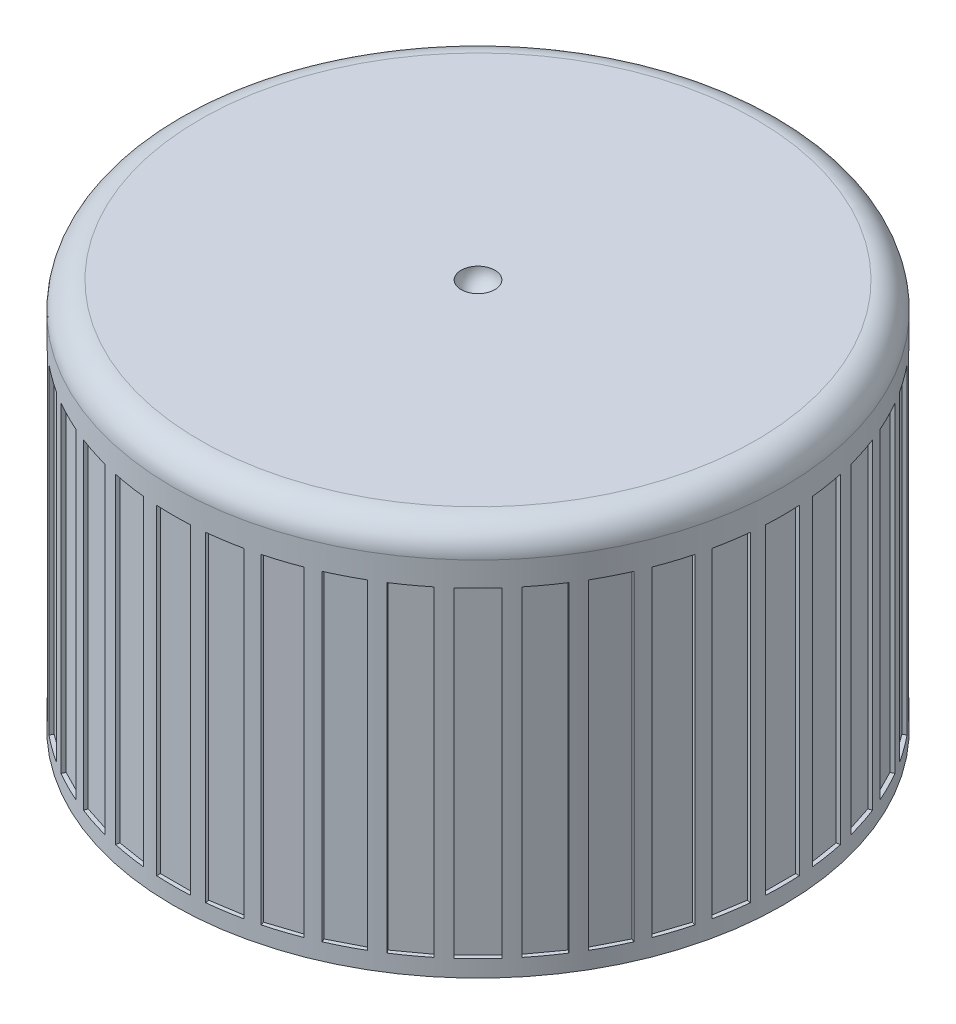
from build123d import *

# Parameters (mm, degrees)
CUT_EXTRUDE1_START = -0.5
SKETCH2_W          = 0.25
SKETCH2_H          = 1
SKETCH2_W_2        = 1
SKETCH2_H_2        = 0.25
CUT_EXTRUDE1_DEPTH = 9.5
FILLET2_R          = 0.8


with BuildPart() as part:
    # Sketch1 → Revolve1 (revolve)
    with BuildSketch(Plane.XY):
        with BuildLine():
            Line((8.23, 11.52), (0.5, 11.52))
            ThreePointArc((0.5, 11.52), (0.353553391, 11.166446609), (0, 11.02))
            Line((0, 11.02), (0, 7.53))
            Line((0, 7.53), (0, 7.23))
            Line((0, 7.23), (2, 7.23))
            Line((2, 7.23), (2, 7.53))
            Line((2, 7.53), (3.5, 7.53))
            ThreePointArc((3.5, 7.53), (3.9, 7.93), (4.3, 7.53))
            Line((4.3, 7.53), (5.51, 7.53))
            Line((5.51, 7.53), (5.51, 10.02))
            Line((5.51, 10.02), (6.73, 10.02))
            ThreePointArc((6.73, 10.02), (7.295685425, 9.785685425), (7.53, 9.22))
            Line((7.53, 9.22), (7.53, 2.04))
            Line((7.53, 2.04), (7.908578644, 1.661421356))
            ThreePointArc((7.908578644, 1.661421356), (7.967157288, 1.52), (7.908578644, 1.378578644))
            Line((7.908578644, 1.378578644), (7.53, 1))
            ThreePointArc((7.53, 1), (7.848120229, 0.29060024), (8.569230485, 0))
            Line((8.569230485, 0), (9.03, 0))
            Line((9.03, 0), (9.03, 10.72))
            ThreePointArc((9.03, 10.72), (8.795685425, 11.285685425), (8.23, 11.52))
        make_face()
    revolve(axis=Axis((0, 0, 0), (0, 1, 0)))

    # Sketch2 → Cut-Extrude1 (cut)
    with BuildSketch(Plane.XZ.offset(CUT_EXTRUDE1_START)):
        Polygon((8.873581906, -0.899204741), (9.120503991, -0.938313357), (8.964069526, -1.926001698), (8.71714744, -1.886893081), align=None)
        with Locations((9.03, 0)):
            Rectangle(SKETCH2_W, SKETCH2_H)
        Polygon((8.623666775, -2.276268077), (8.861430904, -2.353522325), (8.552413909, -3.304578842), (8.31464978, -3.227324593), align=None)
        Polygon((8.161408348, -3.597282138), (8.384159979, -3.710779763), (7.930169479, -4.601786287), (7.707417848, -4.488288662), align=None)
        Polygon((7.498188961, -4.829719174), (7.70044321, -4.976665488), (7.112657957, -5.785682482), (6.910403709, -5.638736169), align=None)
        Polygon((6.650339277, -5.943232496), (6.827115972, -6.120009191), (6.120009191, -6.827115972), (5.943232496, -6.650339277), align=None)
        Polygon((5.638736169, -6.910403709), (5.785682482, -7.112657957), (4.976665488, -7.70044321), (4.829719174, -7.498188961), align=None)
        Polygon((4.488288662, -7.707417848), (4.601786287, -7.930169479), (3.710779763, -8.384159979), (3.597282138, -8.161408348), align=None)
        Polygon((3.227324593, -8.31464978), (3.304578842, -8.552413909), (2.353522325, -8.861430904), (2.276268077, -8.623666775), align=None)
        Polygon((1.886893081, -8.71714744), (1.926001698, -8.964069526), (0.938313357, -9.120503991), (0.899204741, -8.873581906), align=None)
        with Locations((0, -9.03)):
            Rectangle(SKETCH2_W_2, SKETCH2_H_2)
        Polygon((-0.899204741, -8.873581906), (-0.938313357, -9.120503991), (-1.926001698, -8.964069526), (-1.886893081, -8.71714744), align=None)
        Polygon((-2.276268077, -8.623666775), (-2.353522325, -8.861430904), (-3.304578842, -8.552413909), (-3.227324593, -8.31464978), align=None)
        Polygon((-3.597282138, -8.161408348), (-3.710779763, -8.384159979), (-4.601786287, -7.930169479), (-4.488288662, -7.707417848), align=None)
        Polygon((-4.829719174, -7.498188961), (-4.976665488, -7.70044321), (-5.785682482, -7.112657957), (-5.638736169, -6.910403709), align=None)
        Polygon((-5.943232496, -6.650339277), (-6.120009191, -6.827115972), (-6.827115972, -6.120009191), (-6.650339277, -5.943232496), align=None)
        Polygon((-6.910403709, -5.638736169), (-7.112657957, -5.785682482), (-7.70044321, -4.976665488), (-7.498188961, -4.829719174), align=None)
        Polygon((-7.707417848, -4.488288662), (-7.930169479, -4.601786287), (-8.384159979, -3.710779763), (-8.161408348, -3.597282138), align=None)
        Polygon((-8.31464978, -3.227324593), (-8.552413909, -3.304578842), (-8.861430904, -2.353522325), (-8.623666775, -2.276268077), align=None)
        Polygon((-8.71714744, -1.886893081), (-8.964069526, -1.926001698), (-9.120503991, -0.938313357), (-8.873581906, -0.899204741), align=None)
        with Locations((-9.03, 0)):
            Rectangle(SKETCH2_W, SKETCH2_H)
        Polygon((-8.873581906, 0.899204741), (-9.120503991, 0.938313357), (-8.964069526, 1.926001698), (-8.71714744, 1.886893081), align=None)
        Polygon((-8.623666775, 2.276268077), (-8.861430904, 2.353522325), (-8.552413909, 3.304578842), (-8.31464978, 3.227324593), align=None)
        Polygon((-8.161408348, 3.597282138), (-8.384159979, 3.710779763), (-7.930169479, 4.601786287), (-7.707417848, 4.488288662), align=None)
        Polygon((-7.498188961, 4.829719174), (-7.70044321, 4.976665488), (-7.112657957, 5.785682482), (-6.910403709, 5.638736169), align=None)
        Polygon((-6.650339277, 5.943232496), (-6.827115972, 6.120009191), (-6.120009191, 6.827115972), (-5.943232496, 6.650339277), align=None)
        Polygon((-5.638736169, 6.910403709), (-5.785682482, 7.112657957), (-4.976665488, 7.70044321), (-4.829719174, 7.498188961), align=None)
        Polygon((-4.488288662, 7.707417848), (-4.601786287, 7.930169479), (-3.710779763, 8.384159979), (-3.597282138, 8.161408348), align=None)
        Polygon((-3.227324593, 8.31464978), (-3.304578842, 8.552413909), (-2.353522325, 8.861430904), (-2.276268077, 8.623666775), align=None)
        Polygon((-1.886893081, 8.71714744), (-1.926001698, 8.964069526), (-0.938313357, 9.120503991), (-0.899204741, 8.873581906), align=None)
        with Locations((0, 9.03)):
            Rectangle(SKETCH2_W_2, SKETCH2_H_2)
        Polygon((0.899204741, 8.873581906), (0.938313357, 9.120503991), (1.926001698, 8.964069526), (1.886893081, 8.71714744), align=None)
        Polygon((2.276268077, 8.623666775), (2.353522325, 8.861430904), (3.304578842, 8.552413909), (3.227324593, 8.31464978), align=None)
        Polygon((3.597282138, 8.161408348), (3.710779763, 8.384159979), (4.601786287, 7.930169479), (4.488288662, 7.707417848), align=None)
        Polygon((4.829719174, 7.498188961), (4.976665488, 7.70044321), (5.785682482, 7.112657957), (5.638736169, 6.910403709), align=None)
        Polygon((5.943232496, 6.650339277), (6.120009191, 6.827115972), (6.827115972, 6.120009191), (6.650339277, 5.943232496), align=None)
        Polygon((6.910403709, 5.638736169), (7.112657957, 5.785682482), (7.70044321, 4.976665488), (7.498188961, 4.829719174), align=None)
        Polygon((7.707417848, 4.488288662), (7.930169479, 4.601786287), (8.384159979, 3.710779763), (8.161408348, 3.597282138), align=None)
        Polygon((8.31464978, 3.227324593), (8.552413909, 3.304578842), (8.861430904, 2.353522325), (8.623666775, 2.276268077), align=None)
        Polygon((8.71714744, 1.886893081), (8.964069526, 1.926001698), (9.120503991, 0.938313357), (8.873581906, 0.899204741), align=None)
    extrude(amount=-CUT_EXTRUDE1_DEPTH, mode=Mode.SUBTRACT)

    # Fillet2
    fillet2_edges = [part.edges().sort_by_distance(p)[0] for p in [
        (-5.51, 7.53, 0),
    ]]
    fillet(fillet2_edges, radius=FILLET2_R)


solid = part.part
